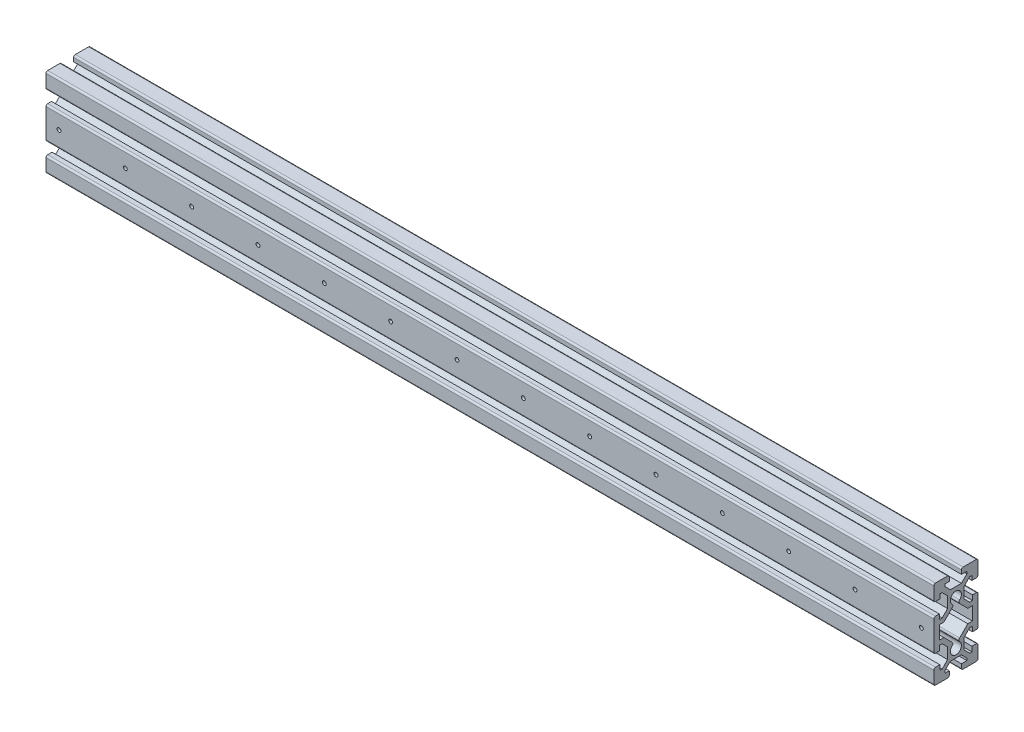
from build123d import *

# Parameters (mm, degrees)
ESTRUSIONE_ESTRUSIONE1_DEPTH = 803
SCHIZZO2_R                   = 1.75
TAGLIO_ESTRUSIONE1_DEPTH     = 10


with BuildPart() as part:
    # Schizzo1 → Estrusione-Estrusione1 (new body)
    with BuildSketch(Plane(origin=(0, 0, 0), x_dir=(0, 0, -1), z_dir=(1, 0, 0))):
        with BuildLine():
            Line((18.5, -39.5), (6.5, -39.5))
            ThreePointArc((6.5, -39.5), (5.439339828, -39.060660172), (5, -38))
            Line((5, -38), (5, -34.5))
            Line((5, -34.5), (9.949747468, -34.5))
            Line((9.949747468, -34.5), (9.949747468, -32.449747468))
            Line((9.949747468, -32.449747468), (5, -27.5))
            Line((5, -27.5), (-5, -27.5))
            Line((-5, -27.5), (-9.949747468, -32.449747468))
            Line((-9.949747468, -32.449747468), (-9.949747468, -34.5))
            Line((-9.949747468, -34.5), (-6, -34.5))
            Line((-6, -34.5), (-6, -38))
            ThreePointArc((-6, -38), (-6.439339828, -39.060660172), (-7.5, -39.5))
            Line((-7.5, -39.5), (-18.5, -39.5))
            ThreePointArc((-18.5, -39.5), (-19.560660172, -39.060660172), (-20, -38))
            Line((-20, -38), (-20, -27))
            ThreePointArc((-20, -27), (-19.560660172, -25.939339828), (-18.5, -25.5))
            Line((-18.5, -25.5), (-14.5, -25.5))
            Line((-14.5, -25.5), (-14.5, -29.949747468))
            Line((-14.5, -29.949747468), (-12.449747468, -29.949747468))
            Line((-12.449747468, -29.949747468), (-7.5, -25))
            Line((-7.5, -25), (-7.5, -15))
            Line((-7.5, -15), (-12.449747468, -10.050252532))
            Line((-12.449747468, -10.050252532), (-15, -10.050252532))
            Line((-15, -10.050252532), (-15, -14.5))
            Line((-15, -14.5), (-18.5, -14.5))
            ThreePointArc((-18.5, -14.5), (-19.560660172, -14.060660172), (-20, -13))
            Line((-20, -13), (-20, 13))
            ThreePointArc((-20, 13), (-19.560660172, 14.060660172), (-18.5, 14.5))
            Line((-18.5, 14.5), (-15, 14.5))
            Line((-15, 14.5), (-15, 10.050252532))
            Line((-15, 10.050252532), (-12.449747468, 10.050252532))
            Line((-12.449747468, 10.050252532), (-7.5, 15))
            Line((-7.5, 15), (-7.5, 25))
            Line((-7.5, 25), (-12.449747468, 29.949747468))
            Line((-12.449747468, 29.949747468), (-14.5, 29.949747468))
            Line((-14.5, 29.949747468), (-14.5, 26))
            Line((-14.5, 26), (-18.5, 26))
            ThreePointArc((-18.5, 26), (-19.560660172, 26.439339828), (-20, 27.5))
            Line((-20, 27.5), (-20, 39))
            ThreePointArc((-20, 39), (-19.560660172, 40.060660172), (-18.5, 40.5))
            Line((-18.5, 40.5), (-7.5, 40.5))
            ThreePointArc((-7.5, 40.5), (-6.439339828, 40.060660172), (-6, 39))
            Line((-6, 39), (-6, 35.5))
            Line((-6, 35.5), (-9.949747468, 35.5))
            Line((-9.949747468, 35.5), (-9.949747468, 33.449747468))
            Line((-9.949747468, 33.449747468), (-5, 28.5))
            Line((-5, 28.5), (5, 28.5))
            Line((5, 28.5), (9.949747468, 33.449747468))
            Line((9.949747468, 33.449747468), (9.949747468, 35.5))
            Line((9.949747468, 35.5), (5, 35.5))
            Line((5, 35.5), (5, 39))
            ThreePointArc((5, 39), (5.439339828, 40.060660172), (6.5, 40.5))
            Line((6.5, 40.5), (18.5, 40.5))
            ThreePointArc((18.5, 40.5), (19.560660172, 40.060660172), (20, 39))
            Line((20, 39), (20, 27.5))
            ThreePointArc((20, 27.5), (19.560660172, 26.439339828), (18.5, 26))
            Line((18.5, 26), (14.5, 26))
            Line((14.5, 26), (14.5, 29.949747468))
            Line((14.5, 29.949747468), (12.449747468, 29.949747468))
            Line((12.449747468, 29.949747468), (7.5, 25))
            Line((7.5, 25), (7.5, 15))
            Line((7.5, 15), (12.449747468, 10.050252532))
            Line((12.449747468, 10.050252532), (15, 10.050252532))
            Line((15, 10.050252532), (15, 14.5))
            Line((15, 14.5), (18.5, 14.5))
            ThreePointArc((18.5, 14.5), (19.560660172, 14.060660172), (20, 13))
            Line((20, 13), (20, -13))
            ThreePointArc((20, -13), (19.560660172, -14.060660172), (18.5, -14.5))
            Line((18.5, -14.5), (15, -14.5))
            Line((15, -14.5), (15, -10.050252532))
            Line((15, -10.050252532), (12.449747468, -10.050252532))
            Line((12.449747468, -10.050252532), (7.5, -15))
            Line((7.5, -15), (7.5, -25))
            Line((7.5, -25), (12.449747468, -29.949747468))
            Line((12.449747468, -29.949747468), (14.5, -29.949747468))
            Line((14.5, -29.949747468), (14.5, -25.5))
            Line((14.5, -25.5), (18.5, -25.5))
            ThreePointArc((18.5, -25.5), (19.560660172, -25.939339828), (20, -27))
            Line((20, -27), (20, -38))
            ThreePointArc((20, -38), (19.560660172, -39.060660172), (18.5, -39.5))
        make_face()
        with BuildLine():
            Line((-15, 6.050252532), (-10.792893219, 6.050252532))
            Line((-10.792893219, 6.050252532), (-3.368595607, 13.474550144))
            ThreePointArc((-3.368595607, 13.474550144), (-2.783084428, 14.921944422), (-3.416292264, 16.349116933))
            ThreePointArc((-3.416292264, 16.349116933), (0, 25), (3.416292264, 16.349116933))
            ThreePointArc((3.416292264, 16.349116933), (2.783084428, 14.921944422), (3.368595607, 13.474550144))
            Line((3.368595607, 13.474550144), (10.792893219, 6.050252532))
            Line((10.792893219, 6.050252532), (15, 6.050252532))
            Line((15, 6.050252532), (15, -6.050252532))
            Line((15, -6.050252532), (10.792893219, -6.050252532))
            Line((10.792893219, -6.050252532), (3.368595607, -13.474550144))
            ThreePointArc((3.368595607, -13.474550144), (2.783084428, -14.921944422), (3.416292264, -16.349116933))
            ThreePointArc((3.416292264, -16.349116933), (0, -25), (-3.416292264, -16.349116933))
            ThreePointArc((-3.416292264, -16.349116933), (-2.783084428, -14.921944422), (-3.368595607, -13.474550144))
            Line((-3.368595607, -13.474550144), (-10.792893219, -6.050252532))
            Line((-10.792893219, -6.050252532), (-15, -6.050252532))
            Line((-15, -6.050252532), (-15, 6.050252532))
        make_face(mode=Mode.SUBTRACT)
    extrude(amount=ESTRUSIONE_ESTRUSIONE1_DEPTH)

    # Schizzo2 → Taglio-Estrusione1 (cut)
    with BuildSketch(Plane.XY.offset(20)):
        with Locations((791.75, 0.5)):
            Circle(SCHIZZO2_R)
        with Locations((731.75, 0.5)):
            Circle(SCHIZZO2_R)
        with Locations((671.75, 0.5)):
            Circle(SCHIZZO2_R)
        with Locations((611.75, 0.5)):
            Circle(SCHIZZO2_R)
        with Locations((551.75, 0.5)):
            Circle(SCHIZZO2_R)
        with Locations((491.75, 0.5)):
            Circle(SCHIZZO2_R)
        with Locations((431.75, 0.5)):
            Circle(SCHIZZO2_R)
        with Locations((371.75, 0.5)):
            Circle(SCHIZZO2_R)
        with Locations((311.75, 0.5)):
            Circle(SCHIZZO2_R)
        with Locations((251.75, 0.5)):
            Circle(SCHIZZO2_R)
        with Locations((191.75, 0.5)):
            Circle(SCHIZZO2_R)
        with Locations((131.75, 0.5)):
            Circle(SCHIZZO2_R)
        with Locations((71.75, 0.5)):
            Circle(SCHIZZO2_R)
        with Locations((11.75, 0.5)):
            Circle(SCHIZZO2_R)
    extrude(amount=-TAGLIO_ESTRUSIONE1_DEPTH, mode=Mode.SUBTRACT)


solid = part.part
